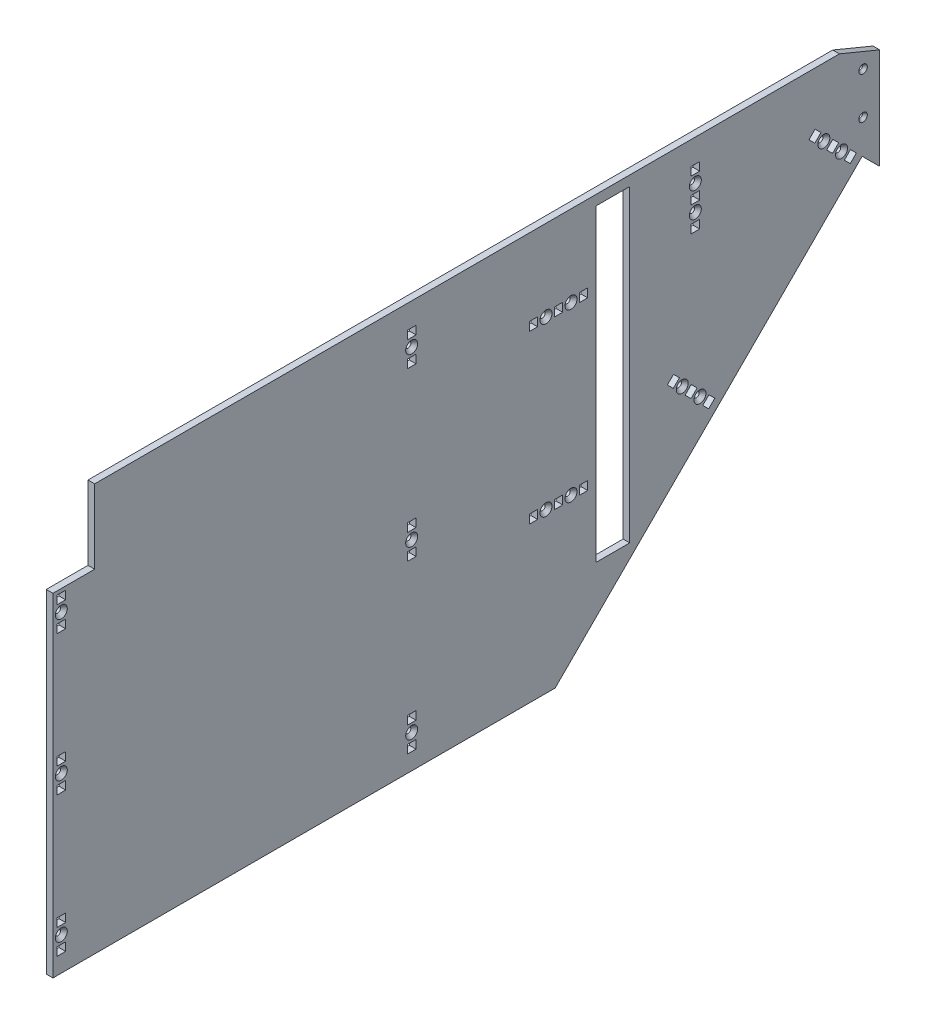
from build123d import *

# Parameters (mm, degrees)
SKETCH1_W                                         = 25.654
SKETCH1_H                                         = 234.95
BOSS_EXTRUDE1_DEPTH                               = 5.08
SKETCH2_W                                         = 31.75
SKETCH2_H                                         = 56.261
CUT_EXTRUDE1_DEPTH                                = 6.08
CHAMFER1_SIZE                                     = 12.7
CHAMFER1_SIZE2                                    = 30.660512242
SKETCH4_R                                         = 2.15265
CUT_EXTRUDE5_DEPTH                                = 6.08
SKETCH5_R                                         = 2.15265
SKETCH5_W                                         = 6.35
SKETCH5_H                                         = 6.604
CUT_EXTRUDE6_DEPTH                                = 6.08
SKETCH6_R                                         = 2.15265
SKETCH6_W                                         = 6.604
SKETCH6_H                                         = 6.35
CUT_EXTRUDE7_DEPTH                                = 6.08
CSK_FOR_8_FLAT_HEAD_SOCKET_CAP_SCREW2_A_COUNT     = 2
CSK_FOR_8_FLAT_HEAD_SOCKET_CAP_SCREW2_A_PITCH     = 106.3625
CSK_FOR_8_FLAT_HEAD_SOCKET_CAP_SCRE_2_COUNT       = 2
CSK_FOR_8_FLAT_HEAD_SOCKET_CAP_SCRE_2_PITCH       = 212.725
CSK_FOR_8_FLAT_HEAD_SOCKET_CAP_SCRE_3_COUNT       = 2
CSK_FOR_8_FLAT_HEAD_SOCKET_CAP_SCRE_3_PITCH       = 341.146325827
CSK_FOR_8_FLAT_HEAD_SOCKET_CAP_SCRE_4_COUNT       = 2
CSK_FOR_8_FLAT_HEAD_SOCKET_CAP_SCRE_4_PITCH       = 280.138654286
CSK_FOR_8_FLAT_HEAD_SOCKET_CAP_SCRE_5_COUNT       = 2
CSK_FOR_8_FLAT_HEAD_SOCKET_CAP_SCRE_5_PITCH       = 269.875
CSK_FOR_8_FLAT_HEAD_SOCKET_CAP_SCRE_6_COUNT       = 2
CSK_FOR_8_FLAT_HEAD_SOCKET_CAP_SCRE_6_PITCH       = 484.361833369
CSK_FOR_8_FLAT_HEAD_SOCKET_CAP_SCRE_7_COUNT       = 2
CSK_FOR_8_FLAT_HEAD_SOCKET_CAP_SCRE_7_PITCH       = 483.111488815
CSK_FOR_8_FLAT_HEAD_SOCKET_CAP_SCRE_8_COUNT       = 2
CSK_FOR_8_FLAT_HEAD_SOCKET_CAP_SCRE_8_PITCH       = 580.761099749
CSK_FOR_8_FLAT_HEAD_SOCKET_CAP_SCRE_9_COUNT       = 2
CSK_FOR_8_FLAT_HEAD_SOCKET_CAP_SCRE_9_PITCH       = 593.921232397
CSK_FOR_8_FLAT_HEAD_SOCKET_CAP_SCRE_10_COUNT      = 2
CSK_FOR_8_FLAT_HEAD_SOCKET_CAP_SCRE_10_PITCH      = 480.717109277
CSK_FOR_8_FLAT_HEAD_SOCKET_CAP_SCRE_11_COUNT      = 2
CSK_FOR_8_FLAT_HEAD_SOCKET_CAP_SCRE_11_PITCH      = 496.535914573
CSK_FOR_8_FLAT_HEAD_SOCKET_CAP_SCRE_12_COUNT      = 2
CSK_FOR_8_FLAT_HEAD_SOCKET_CAP_SCRE_12_PITCH      = 387.032703158
CSK_FOR_8_FLAT_HEAD_SOCKET_CAP_SCRE_13_COUNT      = 2
CSK_FOR_8_FLAT_HEAD_SOCKET_CAP_SCRE_13_PITCH      = 405.232821121
CSK_FOR_8_FLAT_HEAD_SOCKET_CAP_SCRE_14_COUNT      = 2
CSK_FOR_8_FLAT_HEAD_SOCKET_CAP_SCRE_14_PITCH      = 369.071395957
CSK_FOR_8_FLAT_HEAD_SOCKET_CAP_SCRE_15_COUNT      = 2
CSK_FOR_8_FLAT_HEAD_SOCKET_CAP_SCRE_15_PITCH      = 388.114701234
CSK_FOR_4_FLAT_HEAD_SOCKET_CAP_SCREW1_D           = 2.9464
CSK_FOR_4_FLAT_HEAD_SOCKET_CAP_SCREW1_CSINK_D     = 6.477
CSK_FOR_4_FLAT_HEAD_SOCKET_CAP_SCREW1_CSINK_ANGLE = 82


with BuildPart() as part:
    # Sketch1 → Boss-Extrude1 (new body)
    with BuildSketch(Plane(origin=(0, 0, 0), x_dir=(0, 0, -1), z_dir=(1, 0, 0))):
        Polygon((-307.975, 0), (307.975, 0), (321.337621108, 0), (321.337621108, -89.562621108), (307.975, -76.2), (74.295, -309.88), (-307.975, -309.88), align=None)
        with Locations((118.237, -125.095)):
            Rectangle(SKETCH1_W, SKETCH1_H, mode=Mode.SUBTRACT)
    extrude(amount=BOSS_EXTRUDE1_DEPTH)

    # Sketch2 → Cut-Extrude1 (cut, through all)
    with BuildSketch(Plane(origin=(5.08, 0, 0), x_dir=(0, 0, -1), z_dir=(1, 0, 0))):
        with Locations((-292.1, -28.1305)):
            Rectangle(SKETCH2_W, SKETCH2_H)
    extrude(amount=-CUT_EXTRUDE1_DEPTH, mode=Mode.SUBTRACT)

    # Chamfer1
    chamfer1_edges = [part.edges().sort_by_distance(p)[0] for p in [
        (2.54, 0, -321.337621108),
    ]]
    chamfer1_side = [part.faces().sort_by_distance(p)[0] for p in [
        (2.54, -44.781310554, -321.337621108),
    ]]
    chamfer(chamfer1_edges, length=CHAMFER1_SIZE, length2=CHAMFER1_SIZE2, reference=chamfer1_side[0])

    # Sketch4 → Cut-Extrude5 (cut, through all)
    with BuildSketch(Plane(origin=(5.08, 0, 0), x_dir=(0, 0, -1), z_dir=(1, 0, 0))):
        with Locations((278.789167607, -51.683900789)):
            Circle(SKETCH4_R)
        with Locations((292.259551788, -65.154284971)):
            Circle(SKETCH4_R)
        with Locations((171.026094154, -159.446974242)):
            Circle(SKETCH4_R)
        with Locations((184.496478335, -172.917358424)):
            Circle(SKETCH4_R)
        Polygon((285.614162259, -53.839162259), (290.104290319, -58.329290319), (285.434557136, -62.999023502), (280.944429076, -58.508895441), align=None)
        Polygon((272.143778077, -40.368778077), (276.633906137, -44.858906137), (271.964172955, -49.52863932), (267.474044894, -45.03851126), align=None)
        Polygon((299.08454644, -67.30954644), (303.574674501, -71.799674501), (298.904941318, -76.469407684), (294.414813257, -71.979279623), align=None)
        Polygon((177.851088806, -161.602235711), (182.341216866, -166.092363772), (177.671483683, -170.762096955), (173.181355623, -166.271968894), align=None)
        Polygon((164.380704624, -148.13185153), (168.870832685, -152.62197959), (164.201099502, -157.291712773), (159.710971441, -152.801584713), align=None)
        Polygon((191.321472987, -175.072619893), (195.811601048, -179.562747954), (191.141867865, -184.232481136), (186.651739804, -179.742353076), align=None)
    extrude(amount=-CUT_EXTRUDE5_DEPTH, mode=Mode.SUBTRACT)

    # Sketch5 → Cut-Extrude6 (cut, through all)
    with BuildSketch(Plane(origin=(5.08, 0, 0), x_dir=(0, 0, -1), z_dir=(1, 0, 0))):
        with Locations((67.31, -61.722)):
            Circle(SKETCH5_R)
        with Locations((86.36, -61.722)):
            Circle(SKETCH5_R)
        with Locations((67.31, -188.722)):
            Circle(SKETCH5_R)
        with Locations((86.36, -188.722)):
            Circle(SKETCH5_R)
        with Locations((76.835, -61.722)):
            Rectangle(SKETCH5_W, SKETCH5_H)
        with Locations((57.785, -61.722)):
            Rectangle(SKETCH5_W, SKETCH5_H)
        with Locations((95.885, -61.722)):
            Rectangle(SKETCH5_W, SKETCH5_H)
        with Locations((76.835, -188.722)):
            Rectangle(SKETCH5_W, SKETCH5_H)
        with Locations((57.785, -188.722)):
            Rectangle(SKETCH5_W, SKETCH5_H)
        with Locations((95.885, -188.722)):
            Rectangle(SKETCH5_W, SKETCH5_H)
    extrude(amount=-CUT_EXTRUDE6_DEPTH, mode=Mode.SUBTRACT)

    # Sketch6 → Cut-Extrude7 (cut, through all)
    with BuildSketch(Plane(origin=(5.08, 0, 0), x_dir=(0, 0, -1), z_dir=(1, 0, 0))):
        with Locations((180.975, -30.48)):
            Circle(SKETCH6_R)
        with Locations((180.975, -49.53)):
            Circle(SKETCH6_R)
        with Locations((-34.925, -284.48)):
            Circle(SKETCH6_R)
        with Locations((-34.925, -30.48)):
            Circle(SKETCH6_R)
        with Locations((-34.925, -157.48)):
            Circle(SKETCH6_R)
        with Locations((-301.625, -71.755)):
            Circle(SKETCH6_R)
        with Locations((-301.625, -178.1175)):
            Circle(SKETCH6_R)
        with Locations((-301.625, -284.48)):
            Circle(SKETCH6_R)
        with Locations((180.975, -40.005)):
            Rectangle(SKETCH6_W, SKETCH6_H)
        with Locations((180.975, -20.955)):
            Rectangle(SKETCH6_W, SKETCH6_H)
        with Locations((180.975, -59.055)):
            Rectangle(SKETCH6_W, SKETCH6_H)
        with Locations((-34.925, -294.005)):
            Rectangle(SKETCH6_W, SKETCH6_H)
        with Locations((-34.925, -274.955)):
            Rectangle(SKETCH6_W, SKETCH6_H)
        with Locations((-34.925, -40.005)):
            Rectangle(SKETCH6_W, SKETCH6_H)
        with Locations((-34.925, -20.955)):
            Rectangle(SKETCH6_W, SKETCH6_H)
        with Locations((-34.925, -147.955)):
            Rectangle(SKETCH6_W, SKETCH6_H)
        with Locations((-34.925, -167.005)):
            Rectangle(SKETCH6_W, SKETCH6_H)
        with Locations((-301.625, -62.23)):
            Rectangle(SKETCH6_W, SKETCH6_H)
        with Locations((-301.625, -81.28)):
            Rectangle(SKETCH6_W, SKETCH6_H)
        with Locations((-301.625, -168.5925)):
            Rectangle(SKETCH6_W, SKETCH6_H)
        with Locations((-301.625, -187.6425)):
            Rectangle(SKETCH6_W, SKETCH6_H)
        with Locations((-301.625, -274.955)):
            Rectangle(SKETCH6_W, SKETCH6_H)
        with Locations((-301.625, -294.005)):
            Rectangle(SKETCH6_W, SKETCH6_H)
    extrude(amount=-CUT_EXTRUDE7_DEPTH, mode=Mode.SUBTRACT)

    # Sketch9 → CSK for #8 Flat Head Socket Cap Screw2 (revolve, cut)
    with BuildSketch(Plane(origin=(5.08, -71.755, 301.625), x_dir=(0, 0, -1), z_dir=(0, 1, 0))):
        Polygon((0, 0), (0, 5.08), (2.15265, 5.08), (2.15265, 2.768534127), (4.5593, 0), align=None)
    csk_for_8_flat_head_socket_cap_screw2 = revolve(axis=Axis((11.43, -71.755, 301.625), (-1, 0, 0)), mode=Mode.SUBTRACT)

    # CSK for #8 Flat Head Socket Cap Screw2 a: CSK for #8 Flat Head Socket Cap Screw2 ×2
    with Locations(*[(0, -i * CSK_FOR_8_FLAT_HEAD_SOCKET_CAP_SCREW2_A_PITCH, 0) for i in range(1, CSK_FOR_8_FLAT_HEAD_SOCKET_CAP_SCREW2_A_COUNT)]):
        add(csk_for_8_flat_head_socket_cap_screw2, mode=Mode.SUBTRACT)

    # CSK for _8 Flat Head Socket Cap Scre 2: CSK for #8 Flat Head Socket Cap Screw2 ×2
    with Locations(*[(0, -i * CSK_FOR_8_FLAT_HEAD_SOCKET_CAP_SCRE_2_PITCH, 0) for i in range(1, CSK_FOR_8_FLAT_HEAD_SOCKET_CAP_SCRE_2_COUNT)]):
        add(csk_for_8_flat_head_socket_cap_screw2, mode=Mode.SUBTRACT)

    # CSK for _8 Flat Head Socket Cap Scre 3: CSK for #8 Flat Head Socket Cap Screw2 ×2
    with Locations(*[Vector(0, -0.623559405, -0.781775971) * (i * CSK_FOR_8_FLAT_HEAD_SOCKET_CAP_SCRE_3_PITCH) for i in range(1, CSK_FOR_8_FLAT_HEAD_SOCKET_CAP_SCRE_3_COUNT)]):
        add(csk_for_8_flat_head_socket_cap_screw2, mode=Mode.SUBTRACT)

    # CSK for _8 Flat Head Socket Cap Scre 4: CSK for #8 Flat Head Socket Cap Screw2 ×2
    with Locations(*[Vector(0, -0.30600918, -0.952028561) * (i * CSK_FOR_8_FLAT_HEAD_SOCKET_CAP_SCRE_4_PITCH) for i in range(1, CSK_FOR_8_FLAT_HEAD_SOCKET_CAP_SCRE_4_COUNT)]):
        add(csk_for_8_flat_head_socket_cap_screw2, mode=Mode.SUBTRACT)

    # CSK for _8 Flat Head Socket Cap Scre 5: CSK for #8 Flat Head Socket Cap Screw2 ×2
    with Locations(*[Vector(0, 0.152941176, -0.988235294) * (i * CSK_FOR_8_FLAT_HEAD_SOCKET_CAP_SCRE_5_PITCH) for i in range(1, CSK_FOR_8_FLAT_HEAD_SOCKET_CAP_SCRE_5_COUNT)]):
        add(csk_for_8_flat_head_socket_cap_screw2, mode=Mode.SUBTRACT)

    # CSK for _8 Flat Head Socket Cap Scre 6: CSK for #8 Flat Head Socket Cap Screw2 ×2
    with Locations(*[Vector(0, 0.08521522, -0.996362568) * (i * CSK_FOR_8_FLAT_HEAD_SOCKET_CAP_SCRE_6_PITCH) for i in range(1, CSK_FOR_8_FLAT_HEAD_SOCKET_CAP_SCRE_6_COUNT)]):
        add(csk_for_8_flat_head_socket_cap_screw2, mode=Mode.SUBTRACT)

    # CSK for _8 Flat Head Socket Cap Scre 7: CSK for #8 Flat Head Socket Cap Screw2 ×2
    with Locations(*[Vector(0, 0.046003874, -0.998941261) * (i * CSK_FOR_8_FLAT_HEAD_SOCKET_CAP_SCRE_7_PITCH) for i in range(1, CSK_FOR_8_FLAT_HEAD_SOCKET_CAP_SCRE_7_COUNT)]):
        add(csk_for_8_flat_head_socket_cap_screw2, mode=Mode.SUBTRACT)

    # CSK for _8 Flat Head Socket Cap Scre 8: CSK for #8 Flat Head Socket Cap Screw2 ×2
    with Locations(*[Vector(0, 0.034559992, -0.999402625) * (i * CSK_FOR_8_FLAT_HEAD_SOCKET_CAP_SCRE_8_PITCH) for i in range(1, CSK_FOR_8_FLAT_HEAD_SOCKET_CAP_SCRE_8_COUNT)]):
        add(csk_for_8_flat_head_socket_cap_screw2, mode=Mode.SUBTRACT)

    # CSK for _8 Flat Head Socket Cap Scre 9: CSK for #8 Flat Head Socket Cap Screw2 ×2
    with Locations(*[Vector(0, 0.011113789, -0.99993824) * (i * CSK_FOR_8_FLAT_HEAD_SOCKET_CAP_SCRE_9_PITCH) for i in range(1, CSK_FOR_8_FLAT_HEAD_SOCKET_CAP_SCRE_9_COUNT)]):
        add(csk_for_8_flat_head_socket_cap_screw2, mode=Mode.SUBTRACT)

    # CSK for _8 Flat Head Socket Cap Scre 10: CSK for #8 Flat Head Socket Cap Screw2 ×2
    with Locations(*[Vector(0, -0.182419083, -0.983220869) * (i * CSK_FOR_8_FLAT_HEAD_SOCKET_CAP_SCRE_10_PITCH) for i in range(1, CSK_FOR_8_FLAT_HEAD_SOCKET_CAP_SCRE_10_COUNT)]):
        add(csk_for_8_flat_head_socket_cap_screw2, mode=Mode.SUBTRACT)

    # CSK for _8 Flat Head Socket Cap Scre 11: CSK for #8 Flat Head Socket Cap Screw2 ×2
    with Locations(*[Vector(0, -0.203736236, -0.979025815) * (i * CSK_FOR_8_FLAT_HEAD_SOCKET_CAP_SCRE_11_PITCH) for i in range(1, CSK_FOR_8_FLAT_HEAD_SOCKET_CAP_SCRE_11_COUNT)]):
        add(csk_for_8_flat_head_socket_cap_screw2, mode=Mode.SUBTRACT)

    # CSK for _8 Flat Head Socket Cap Scre 12: CSK for #8 Flat Head Socket Cap Screw2 ×2
    with Locations(*[Vector(0, -0.302214772, -0.953239861) * (i * CSK_FOR_8_FLAT_HEAD_SOCKET_CAP_SCRE_12_PITCH) for i in range(1, CSK_FOR_8_FLAT_HEAD_SOCKET_CAP_SCRE_12_COUNT)]):
        add(csk_for_8_flat_head_socket_cap_screw2, mode=Mode.SUBTRACT)

    # CSK for _8 Flat Head Socket Cap Scre 13: CSK for #8 Flat Head Socket Cap Screw2 ×2
    with Locations(*[Vector(0, -0.288641477, -0.957437255) * (i * CSK_FOR_8_FLAT_HEAD_SOCKET_CAP_SCRE_13_PITCH) for i in range(1, CSK_FOR_8_FLAT_HEAD_SOCKET_CAP_SCRE_13_COUNT)]):
        add(csk_for_8_flat_head_socket_cap_screw2, mode=Mode.SUBTRACT)

    # CSK for _8 Flat Head Socket Cap Scre 14: CSK for #8 Flat Head Socket Cap Screw2 ×2
    with Locations(*[Vector(0, 0.027184442, -0.999630435) * (i * CSK_FOR_8_FLAT_HEAD_SOCKET_CAP_SCRE_14_PITCH) for i in range(1, CSK_FOR_8_FLAT_HEAD_SOCKET_CAP_SCRE_14_COUNT)]):
        add(csk_for_8_flat_head_socket_cap_screw2, mode=Mode.SUBTRACT)

    # CSK for _8 Flat Head Socket Cap Scre 15: CSK for #8 Flat Head Socket Cap Screw2 ×2
    with Locations(*[Vector(0, 0.025850605, -0.999665817) * (i * CSK_FOR_8_FLAT_HEAD_SOCKET_CAP_SCRE_15_PITCH) for i in range(1, CSK_FOR_8_FLAT_HEAD_SOCKET_CAP_SCRE_15_COUNT)]):
        add(csk_for_8_flat_head_socket_cap_screw2, mode=Mode.SUBTRACT)

    # CSK for #4 Flat Head Socket Cap Screw1 (through all)
    with Locations(Plane(origin=(5.08, 0, 0), x_dir=(0, 0, -1), z_dir=(1, 0, 0))):
        with Locations((308.637621108, -19.05), (308.637621108, -50.8)):
            CounterSinkHole(CSK_FOR_4_FLAT_HEAD_SOCKET_CAP_SCREW1_D / 2, CSK_FOR_4_FLAT_HEAD_SOCKET_CAP_SCREW1_CSINK_D / 2, counter_sink_angle=CSK_FOR_4_FLAT_HEAD_SOCKET_CAP_SCREW1_CSINK_ANGLE)


solid = part.part
